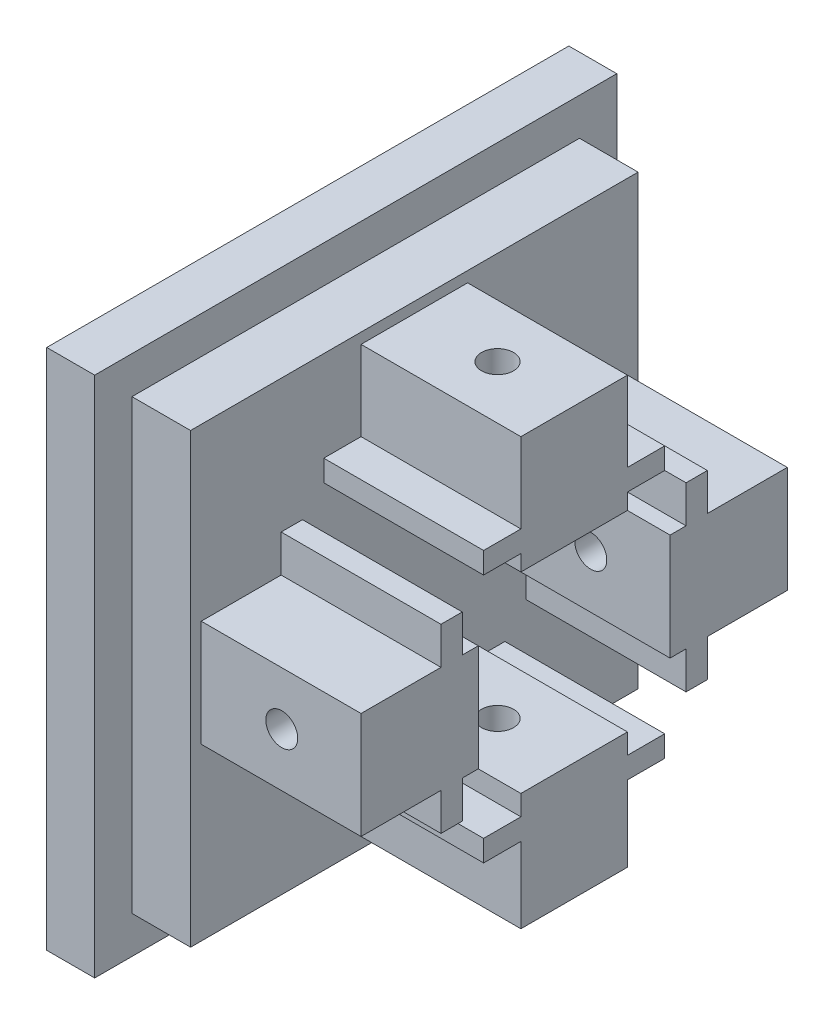
from build123d import *

# Parameters (mm, degrees)
SKETCH1_W                 = 49
SKETCH1_H                 = 49
BOSS_EXTRUDE1_DEPTH       = 4.5
SKETCH3_W                 = 42
SKETCH3_H                 = 42
BOSS_EXTRUDE3_DEPTH       = 5.5
SKETCH4_W                 = 11
SKETCH4_H                 = 10
SKETCH4_W_2               = 10
SKETCH4_H_2               = 11
BOSS_EXTRUDE5_DEPTH       = 15
F_3_0MM_DOWEL_SLOT1_D     = 3
F_3_0MM_DOWEL_SLOT2_D     = 3
SKETCH15_W                = 15
SKETCH15_H                = 2
BOSS_EXTRUDE7_DEPTH       = 3.5
BOSS_EXTRUDE7_DEPTH_BACK  = 13.5
F_3_0MM_DOWEL_SLOT3_D     = 3
SKETCH18_W                = 15
SKETCH18_H                = 2
BOSS_EXTRUDE8_DEPTH       = 3.5
BOSS_EXTRUDE8_DEPTH_BACK  = 13.5
F_3_0MM_DOWEL_SLOT5_D     = 3
SKETCH23_W                = 15
SKETCH23_H                = 2
BOSS_EXTRUDE9_DEPTH       = 3.5
BOSS_EXTRUDE9_DEPTH_BACK  = 13.5
SKETCH24_W                = 15
SKETCH24_H                = 2
BOSS_EXTRUDE10_DEPTH      = 3.5
BOSS_EXTRUDE10_DEPTH_BACK = 13.5
F_3_0MM_DOWEL_SLOT6_D     = 3


with BuildPart() as part:
    # Sketch1 → Boss-Extrude1 (new body)
    with BuildSketch(Plane(origin=(0, 0, 0), x_dir=(0, 0, -1), z_dir=(1, 0, 0))):
        Rectangle(SKETCH1_W, SKETCH1_H)
    extrude(amount=BOSS_EXTRUDE1_DEPTH)

    # Sketch3 → Boss-Extrude3 (add)
    with BuildSketch(Plane(origin=(4.5, 0, 0), x_dir=(0, 0, -1), z_dir=(1, 0, 0))):
        Rectangle(SKETCH3_W, SKETCH3_H)
    extrude(amount=BOSS_EXTRUDE3_DEPTH)

    # Sketch4 → Boss-Extrude5 (add)
    with BuildSketch(Plane(origin=(10, 0, 0), x_dir=(0, 0, -1), z_dir=(1, 0, 0))):
        with Locations((14.5, 0)):
            Rectangle(SKETCH4_W, SKETCH4_H)
        with Locations((0, -14.5)):
            Rectangle(SKETCH4_W_2, SKETCH4_H_2)
        with Locations((-14.5, 0)):
            Rectangle(SKETCH4_W, SKETCH4_H)
        with Locations((0, 14.5)):
            Rectangle(SKETCH4_W_2, SKETCH4_H_2)
    extrude(amount=BOSS_EXTRUDE5_DEPTH)

    # Ø3.0mm Dowel Slot1 (through all)
    with Locations(Plane(origin=(0, 0, -20), x_dir=(-1, 0, 0), z_dir=(0, 0, -1))):
        with Locations((-17.558984138, 0)):
            Hole(F_3_0MM_DOWEL_SLOT1_D / 2)

    # Ø3.0mm Dowel Slot2 (through all)
    with Locations(Plane(origin=(0, 20, 0), x_dir=(1, 0, 0), z_dir=(0, 1, 0))):
        with Locations((17.80910446, 0)):
            Hole(F_3_0MM_DOWEL_SLOT2_D / 2)

    # Sketch15 → Boss-Extrude7 (add, two sides)
    with BuildSketch(Plane.XY.offset(5)) as boss_extrude7_sk:
        with Locations((17.5, -11.9)):
            Rectangle(SKETCH15_W, SKETCH15_H)
    extrude(amount=BOSS_EXTRUDE7_DEPTH)
    extrude(boss_extrude7_sk.sketch, amount=-BOSS_EXTRUDE7_DEPTH_BACK)

    # Ø3.0mm Dowel Slot3 (through all)
    with Locations(Plane(origin=(17.80910446, -20, 0), x_dir=(0, 0, -1), z_dir=(0, -1, 0))):
        with Locations((0, 0)):
            Hole(F_3_0MM_DOWEL_SLOT3_D / 2)

    # Sketch18 → Boss-Extrude8 (add, two sides)
    with BuildSketch(Plane(origin=(0, 0, -5), x_dir=(-1, 0, 0), z_dir=(0, 0, -1))) as boss_extrude8_sk:
        with Locations((-17.5, 11.5)):
            Rectangle(SKETCH18_W, SKETCH18_H)
    extrude(amount=BOSS_EXTRUDE8_DEPTH)
    extrude(boss_extrude8_sk.sketch, amount=-BOSS_EXTRUDE8_DEPTH_BACK)

    # Ø3.0mm Dowel Slot5 (through all)
    with Locations(Plane(origin=(0, 20, 0), x_dir=(1, 0, 0), z_dir=(0, 1, 0))):
        with Locations((17.80910446, 0)):
            Hole(F_3_0MM_DOWEL_SLOT5_D / 2)

    # Sketch23 → Boss-Extrude9 (add, two sides)
    with BuildSketch(Plane.XZ.offset(5)) as boss_extrude9_sk:
        with Locations((17.5, -11.5)):
            Rectangle(SKETCH23_W, SKETCH23_H)
    extrude(amount=BOSS_EXTRUDE9_DEPTH)
    extrude(boss_extrude9_sk.sketch, amount=-BOSS_EXTRUDE9_DEPTH_BACK)

    # Sketch24 → Boss-Extrude10 (add, two sides)
    with BuildSketch(Plane.XZ.offset(5)) as boss_extrude10_sk:
        with Locations((17.5, 11.5)):
            Rectangle(SKETCH24_W, SKETCH24_H)
    extrude(amount=BOSS_EXTRUDE10_DEPTH)
    extrude(boss_extrude10_sk.sketch, amount=-BOSS_EXTRUDE10_DEPTH_BACK)

    # Ø3.0mm Dowel Slot6 (through all)
    with Locations(Plane.XY.offset(20)):
        with Locations((17.558984138, 0)):
            Hole(F_3_0MM_DOWEL_SLOT6_D / 2)


solid = part.part
